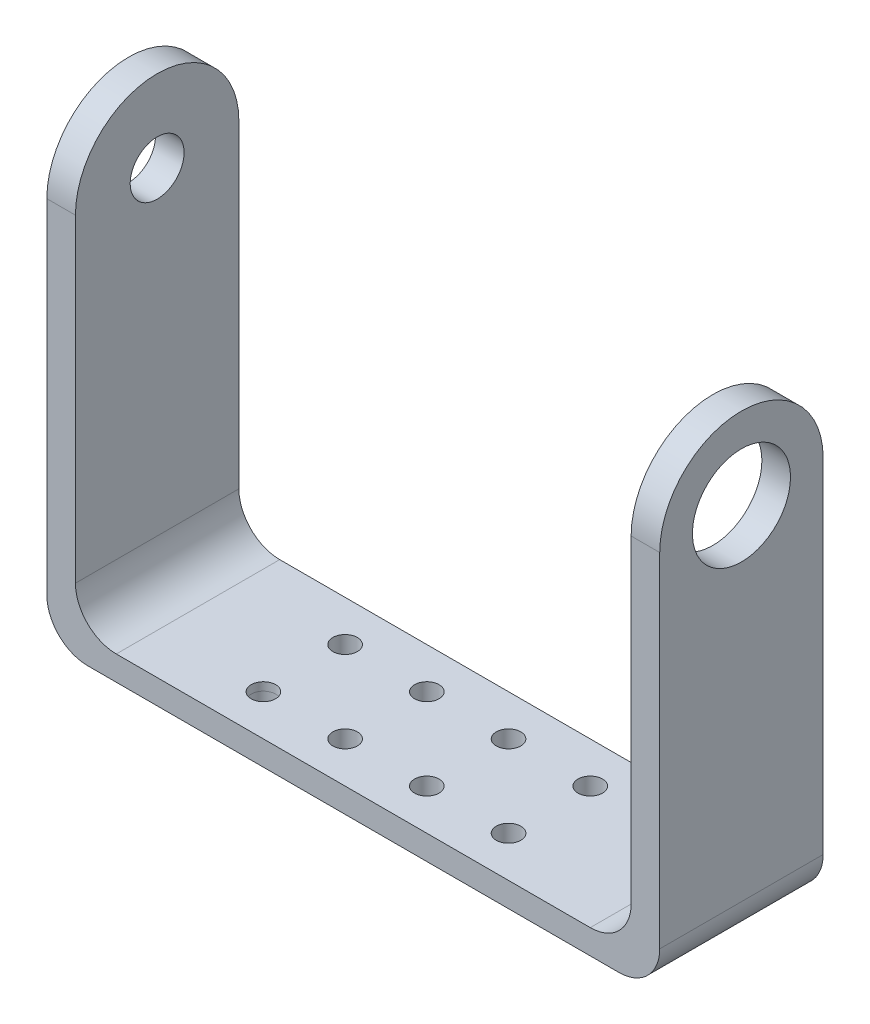
from build123d import *

# Parameters (mm, degrees)
SKETCH_2_R          = 1.5
EXTRUDE_1_DEPTH     = 2
SKETCH_3_W          = 2
SKETCH_3_H          = 20
SKETCH_3_W_2        = 3.5
EXTRUDE_2_DEPTH     = 55
SKETCH_9_R          = 6
CUT_EXTRUDE_1_DEPTH = 87
SKETCH_7_R          = 6
SKETCH_7_R_2        = 3.3
EXTRUDE_3_DEPTH     = 2
SKETCH_10_R         = 3.3
EXTRUDE_4_DEPTH     = 1.5
SKETCH_11_W         = 68
SKETCH_11_H         = 20
SKETCH_11_R         = 1.5
SKETCH_11_R_2       = 1.498871695
EXTRUDE_5_DEPTH     = 1
FILLET_6_R          = 5
FILLET_7_R          = 5
FILLET_8_R          = 5


with BuildPart() as part:
    # 스케치2 → 보스-돌출1 (new body)
    with BuildSketch(Plane(origin=(0, 0, 0), x_dir=(1, 0, 0), z_dir=(0, 1, 0))):
        Polygon((35, -10), (-35, -10), (-35, 10), (35, 10), (38.5, 10), (38.5, -10), align=None)
        with Locations((-15, 5)):
            Circle(SKETCH_2_R, mode=Mode.SUBTRACT)
        with Locations((-5, 5)):
            Circle(SKETCH_2_R, mode=Mode.SUBTRACT)
        with Locations((-15, -5)):
            Circle(SKETCH_2_R, mode=Mode.SUBTRACT)
        with Locations((-5, -5)):
            Circle(SKETCH_2_R, mode=Mode.SUBTRACT)
        with Locations((15, -5)):
            Circle(SKETCH_2_R, mode=Mode.SUBTRACT)
        with Locations((5, -5)):
            Circle(SKETCH_2_R, mode=Mode.SUBTRACT)
        with Locations((5, 5)):
            Circle(SKETCH_2_R, mode=Mode.SUBTRACT)
        with Locations((15, 5)):
            Circle(SKETCH_2_R, mode=Mode.SUBTRACT)
    extrude(amount=EXTRUDE_1_DEPTH)

    # 스케치3 → 보스-돌출2 (add)
    with BuildSketch(Plane(origin=(0, 2, 0), x_dir=(1, 0, 0), z_dir=(0, 1, 0))):
        with Locations((-34, 0)):
            Rectangle(SKETCH_3_W, SKETCH_3_H)
        with Locations((36.75, 0)):
            Rectangle(SKETCH_3_W_2, SKETCH_3_H)
    extrude(amount=EXTRUDE_2_DEPTH)

    # 스케치9 → 컷-돌출1 (cut)
    with BuildSketch(Plane(origin=(38.5, 0, 0), x_dir=(0, 0, -1), z_dir=(1, 0, 0))):
        with BuildLine():
            Line((10, 57), (0, 57))
            ThreePointArc((0, 57), (7.071067812, 54.071067812), (10, 47))
            Line((10, 47), (10, 57))
        make_face()
        with BuildLine():
            Line((-10, 57), (-10, 47))
            ThreePointArc((-10, 47), (-7.071067812, 54.071067812), (0, 57))
            Line((0, 57), (-10, 57))
        make_face()
        with Locations((0, 47)):
            Circle(SKETCH_9_R)
    extrude(amount=-CUT_EXTRUDE_1_DEPTH, mode=Mode.SUBTRACT)

    # 스케치7 → 보스-돌출3 (add)
    with BuildSketch(Plane.ZY.offset(35)):
        with Locations((0, 47)):
            Circle(SKETCH_7_R)
        with Locations((0, 47)):
            Circle(SKETCH_7_R_2, mode=Mode.SUBTRACT)
    extrude(amount=-EXTRUDE_3_DEPTH)

    # 스케치10 → 보스-돌출4 (add)
    with BuildSketch(Plane.ZY.offset(35)):
        with BuildLine():
            ThreePointArc((-10, 47), (0, 57), (10, 47))
            Line((10, 47), (10, 0))
            Line((10, 0), (-10, 0))
            Line((-10, 0), (-10, 47))
        make_face()
        with Locations((0, 47)):
            Circle(SKETCH_10_R, mode=Mode.SUBTRACT)
    extrude(amount=EXTRUDE_4_DEPTH)

    # 스케치11 → 보스-돌출5 (add)
    with BuildSketch(Plane(origin=(0, 2, 0), x_dir=(1, 0, 0), z_dir=(0, 1, 0))):
        with Locations((1, 0)):
            Rectangle(SKETCH_11_W, SKETCH_11_H)
        with Locations((-15, 5)):
            Circle(SKETCH_11_R, mode=Mode.SUBTRACT)
        with Locations((-5, 5)):
            Circle(SKETCH_11_R, mode=Mode.SUBTRACT)
        with Locations((5, 5)):
            Circle(SKETCH_11_R, mode=Mode.SUBTRACT)
        with Locations((15, 5)):
            Circle(SKETCH_11_R, mode=Mode.SUBTRACT)
        with Locations((15, -5)):
            Circle(SKETCH_11_R, mode=Mode.SUBTRACT)
        with Locations((5, -5)):
            Circle(SKETCH_11_R, mode=Mode.SUBTRACT)
        with Locations((-5, -5)):
            Circle(SKETCH_11_R, mode=Mode.SUBTRACT)
        with Locations((-15, -5)):
            Circle(SKETCH_11_R_2, mode=Mode.SUBTRACT)
    extrude(amount=EXTRUDE_5_DEPTH)

    # 필렛6
    fillet_6_edges = [part.edges().sort_by_distance(p)[0] for p in [
        (-33, 3, 0),
    ]]
    fillet(fillet_6_edges, radius=FILLET_6_R)

    # 필렛7
    fillet_7_edges = [part.edges().sort_by_distance(p)[0] for p in [
        (35, 3, 0),
    ]]
    fillet(fillet_7_edges, radius=FILLET_7_R)

    # 필렛8
    fillet_8_edges = [part.edges().sort_by_distance(p)[0] for p in [
        (-36.5, 0, 0),
        (38.5, 0, 0),
    ]]
    fillet(fillet_8_edges, radius=FILLET_8_R)


solid = part.part
